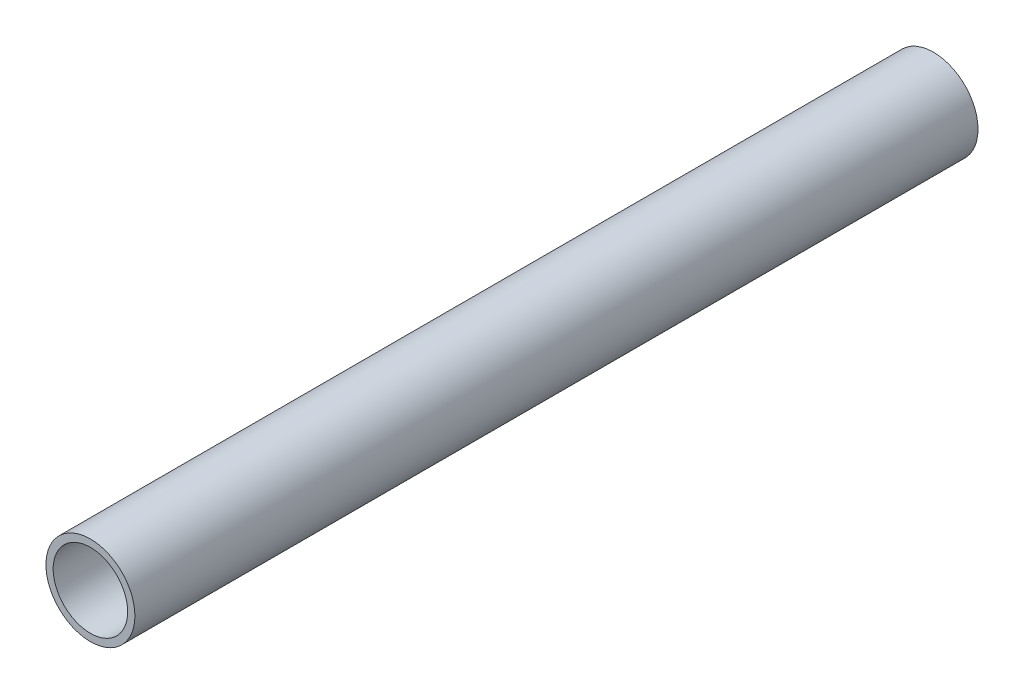
from build123d import *

# Parameters (mm, degrees)
SKETCH1_R           = 24.13
SKETCH1_R_2         = 20.193
BOSS_EXTRUDE1_DEPTH = 457.2


with BuildPart() as part:
    # Sketch1 → Boss-Extrude1 (new body)
    with BuildSketch(Plane.XY):
        Circle(SKETCH1_R)
        Circle(SKETCH1_R_2, mode=Mode.SUBTRACT)
    extrude(amount=BOSS_EXTRUDE1_DEPTH)


solid = part.part
